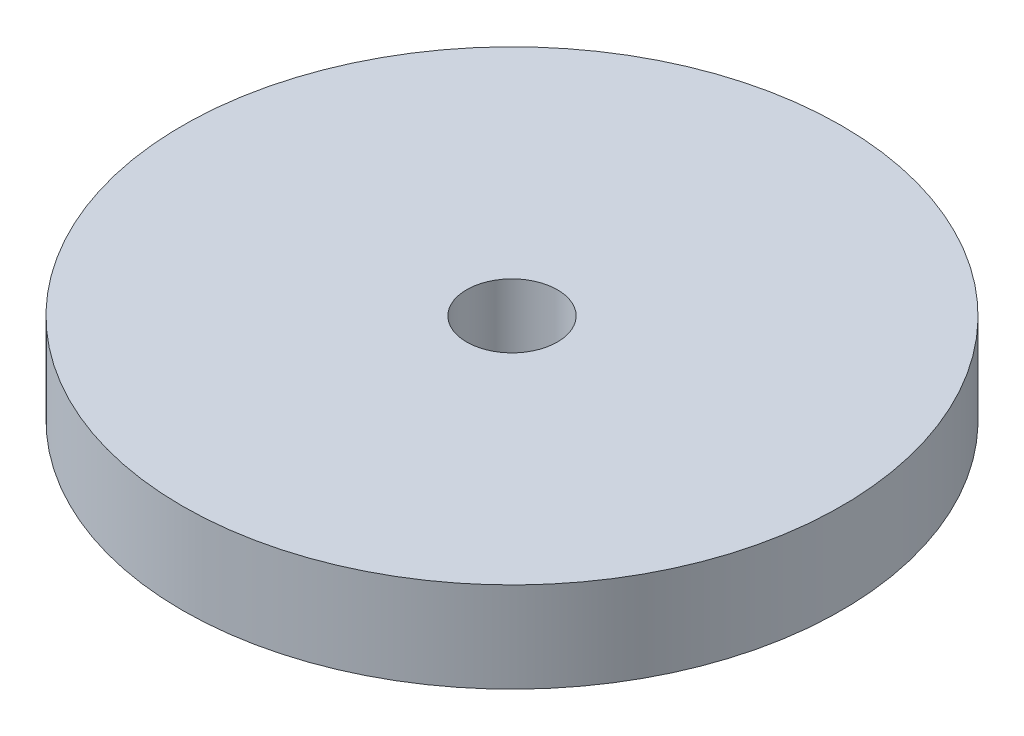
from build123d import *

# Parameters (mm, degrees)
SKETCH1_R               = 18.542
BOSS_EXTRUDE1_DEPTH     = 5.08
F_1_4_20_TAPPED_HOLE1_D = 5.1054


with BuildPart() as part:
    # Sketch1 → Boss-Extrude1 (new body)
    with BuildSketch(Plane(origin=(0, 0, 0), x_dir=(1, 0, 0), z_dir=(0, 1, 0))):
        with Locations(Location((0, 0, 0), (0, 0, 270))):  # turned: the seam where the file's is
            Circle(SKETCH1_R)
    extrude(amount=BOSS_EXTRUDE1_DEPTH)

    # 1/4-20 Tapped Hole1 (through all)
    with Locations(Plane(origin=(0, 5.08, 0), x_dir=(1, 0, 0), z_dir=(0, 1, 0))):
        with Locations((0, 0)):
            Hole(F_1_4_20_TAPPED_HOLE1_D / 2)


solid = part.part
